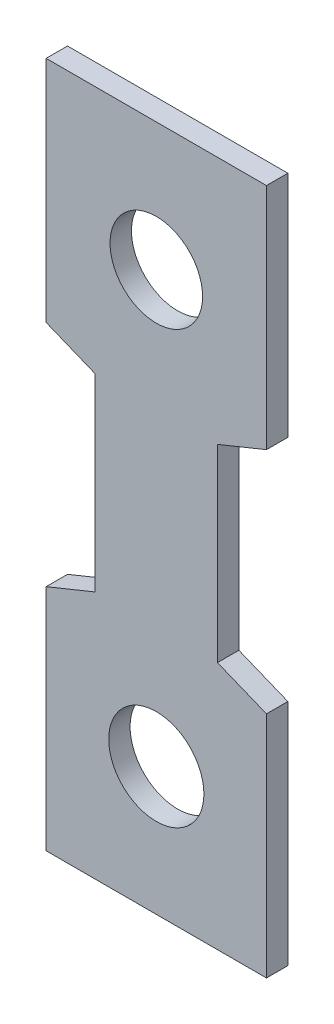
from build123d import *

# Parameters (mm, degrees)
SKETCH1_R           = 2.430870735
SKETCH1_R_2         = 2.36295848
BOSS_EXTRUDE1_DEPTH = 1.0922


with BuildPart() as part:
    # Sketch1 → Boss-Extrude1 (new body)
    with BuildSketch(Plane.XY):
        Polygon((-5.6261, 28.5115), (5.6261, 28.5115), (5.6261, 16.8275), (3.1242, 15.8115), (3.1242, 6.1595), (5.6261, 5.1435), (5.6261, -6.5405), (-5.6261, -6.5405), (-5.6261, 5.1435), (-3.1242, 6.1595), (-3.1242, 15.8115), (-5.6261, 16.8275), align=None)
        Circle(SKETCH1_R, mode=Mode.SUBTRACT)
        with Locations((0, 21.971)):
            Circle(SKETCH1_R_2, mode=Mode.SUBTRACT)
    extrude(amount=BOSS_EXTRUDE1_DEPTH)


solid = part.part
